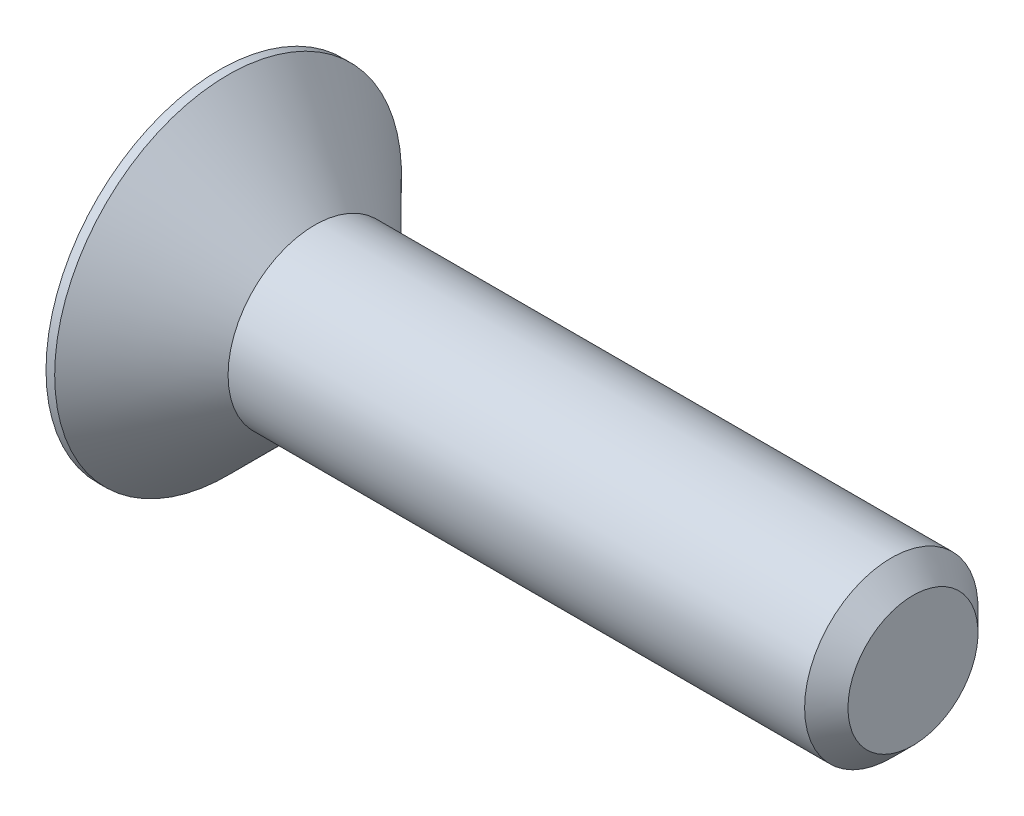
from build123d import *

# Parameters (mm, degrees)
CUT_EXTRUDE1_DEPTH = 0.8


with BuildPart() as part:
    # Sketch2 → Revolve1 (revolve)
    with BuildSketch(Plane.XY):
        Polygon((0, 0), (0, 2), (0.1, 2), (1.1, 1), (7.75, 1), (8, 0.75), (8, 0), align=None)
    revolve(axis=Axis((-2.281841559, 0, 0), (1, 0, 0)))

    # Sketch3 → Cut-Extrude1 (cut)
    with BuildSketch(Plane.ZY):
        Polygon((0.433012702, -0.75), (0.866025404, 0), (0.433012702, 0.75), (-0.433012702, 0.75), (-0.866025404, 0), (-0.433012702, -0.75), align=None)
    extrude(amount=-CUT_EXTRUDE1_DEPTH, mode=Mode.SUBTRACT)


solid = part.part
